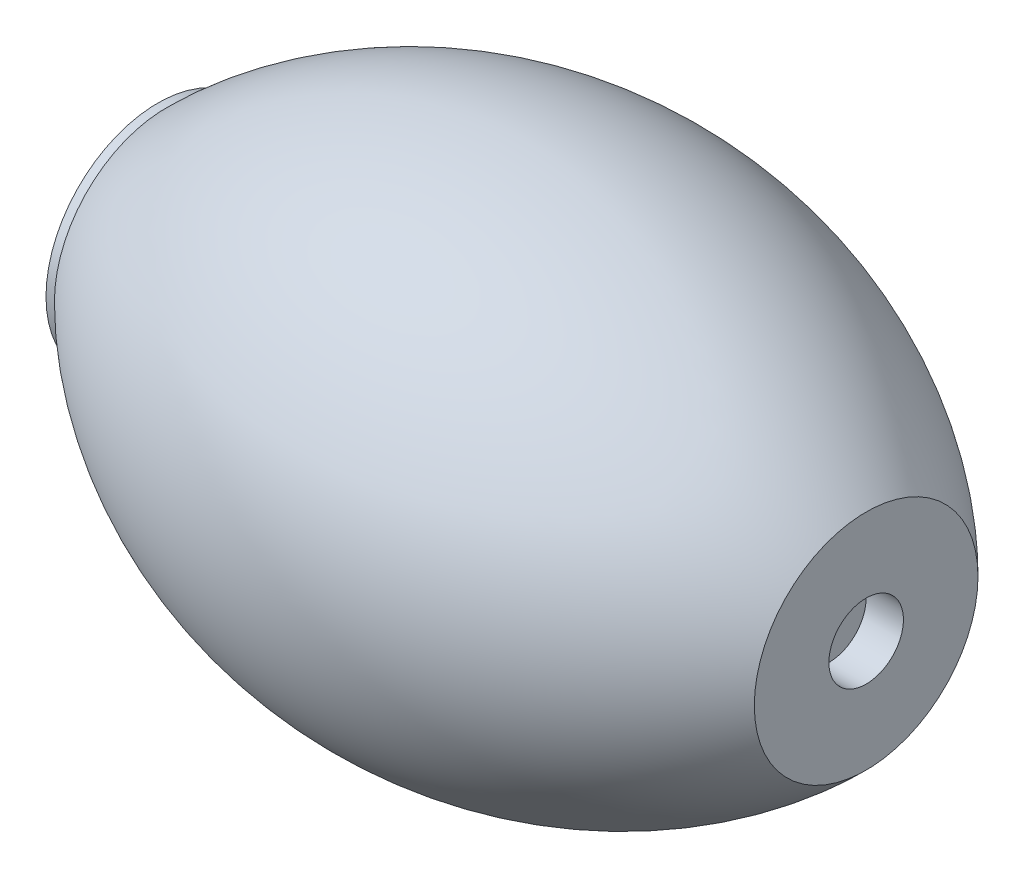
from build123d import *


with BuildPart() as part:
    # Sketch1 → Revolve1 (revolve)
    with BuildSketch(Plane.XY):
        with BuildLine():
            Line((-482.6, 0), (-482.6, -50.8))
            Line((-482.6, -50.8), (-457.2, -50.8))
            Line((-457.2, -50.8), (-457.2, -76.2))
            Line((-457.2, -76.2), (-25.4, -76.2))
            Line((-25.4, -76.2), (-25.4, -50.8))
            Line((-25.4, -50.8), (0, -50.8))
            Line((0, -50.8), (0, 0))
            ThreePointArc((0, 0), (-238.434509563, 98.762807599), (-476.869019126, 0))
            Line((-476.869019126, 0), (-482.6, 0))
        make_face()
    revolve(axis=Axis((-457.2, -76.2, 0), (1, 0, 0)))


solid = part.part
